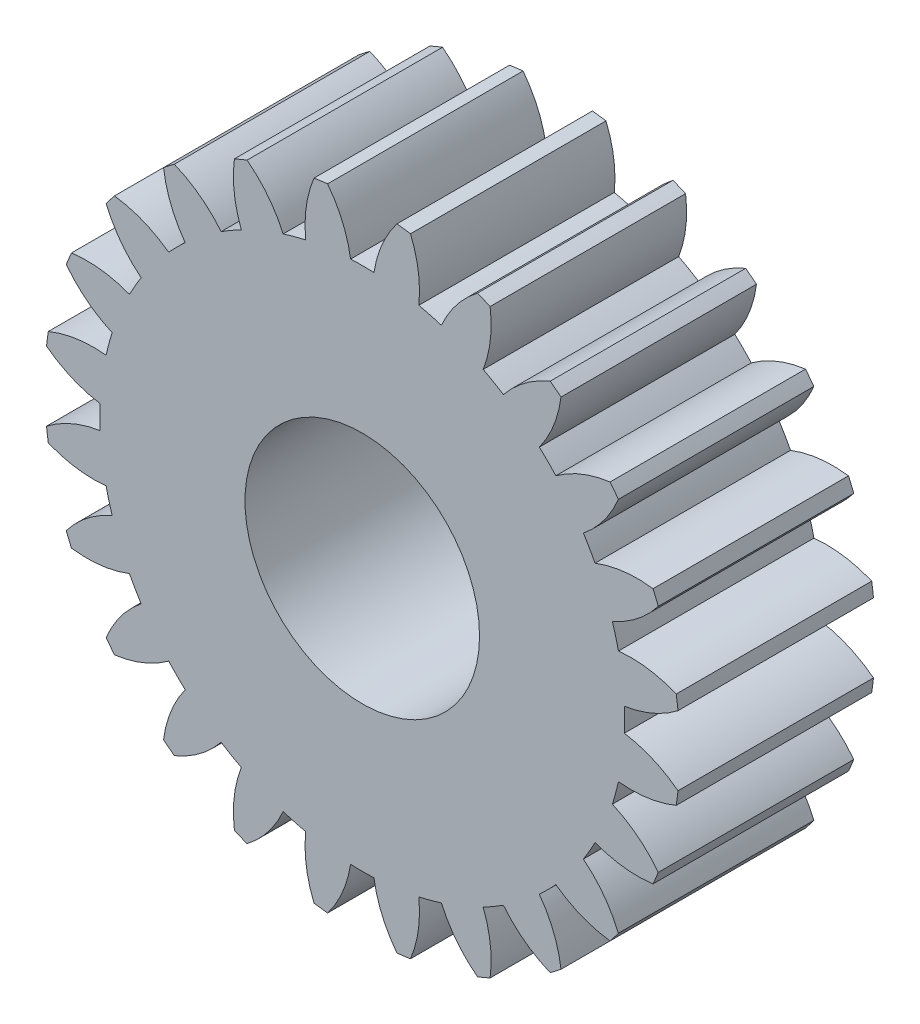
from build123d import *

# Parameters (mm, degrees)
SKETCH2_R           = 3.81
BOSS_EXTRUDE1_DEPTH = 6.35


with BuildPart() as part:
    # Sketch2 → Boss-Extrude1 (new body)
    with BuildSketch(Plane.XY):
        with BuildLine():
            ThreePointArc((-42.015017319, -22.945367918), (-41.531469039, -22.120633406), (-41.268457962, -21.20148645))
            ThreePointArc((-41.268457962, -21.20148645), (-40.889005651, -21.209938725), (-40.50955334, -21.20148645))
            ThreePointArc((-40.50955334, -21.20148645), (-40.246542262, -22.120633406), (-39.762993983, -22.945367918))
            ThreePointArc((-39.762993983, -22.945367918), (-39.542138505, -22.918710388), (-39.321909019, -22.887297981))
            ThreePointArc((-39.321909019, -22.887297981), (-39.068294246, -21.965514112), (-39.052137791, -21.009614053))
            ThreePointArc((-39.052137791, -21.009614053), (-38.683427394, -20.919568839), (-38.319092217, -20.813195084))
            ThreePointArc((-38.319092217, -20.813195084), (-37.827150287, -21.632950591), (-37.146621516, -22.304431452))
            ThreePointArc((-37.146621516, -22.304431452), (-36.940190983, -22.221520651), (-36.735595764, -22.13417901))
            ThreePointArc((-36.735595764, -22.13417901), (-36.729197926, -21.178163832), (-36.960997129, -20.250653679))
            ThreePointArc((-36.960997129, -20.250653679), (-36.628155651, -20.068247408), (-36.303766447, -19.871201369))
            ThreePointArc((-36.303766447, -19.871201369), (-35.616418695, -20.535700443), (-34.785286345, -21.008167342))
            ThreePointArc((-34.785286345, -21.008167342), (-34.607348655, -20.874653505), (-34.432330529, -20.737334819))
            ThreePointArc((-34.432330529, -20.737334819), (-34.673585627, -19.812239186), (-35.137543756, -18.976327224))
            ThreePointArc((-35.137543756, -18.976327224), (-34.863253794, -18.713990582), (-34.600917152, -18.43970062))
            ThreePointArc((-34.600917152, -18.43970062), (-33.76500519, -18.903658748), (-32.839909556, -19.144913847))
            ThreePointArc((-32.839909556, -19.144913847), (-32.702590871, -18.969895721), (-32.569077034, -18.791958031))
            ThreePointArc((-32.569077034, -18.791958031), (-33.041543932, -17.960825681), (-33.706043007, -17.273477928))
            ThreePointArc((-33.706043007, -17.273477928), (-33.508996967, -16.949088725), (-33.326590697, -16.616247247))
            ThreePointArc((-33.326590697, -16.616247247), (-32.399080544, -16.84804645), (-31.443065365, -16.841648612))
            ThreePointArc((-31.443065365, -16.841648612), (-31.355723725, -16.637053393), (-31.272812924, -16.430622859))
            ThreePointArc((-31.272812924, -16.430622859), (-31.944293785, -15.750094089), (-32.764049292, -15.258152159))
            ThreePointArc((-32.764049292, -15.258152159), (-32.657675537, -14.893816982), (-32.567630323, -14.525106585))
            ThreePointArc((-32.567630323, -14.525106585), (-31.611730264, -14.50895013), (-30.689946395, -14.255335357))
            ThreePointArc((-30.689946395, -14.255335357), (-30.658533987, -14.035105871), (-30.631876458, -13.814250393))
            ThreePointArc((-30.631876458, -13.814250393), (-31.456610969, -13.330702114), (-32.375757925, -13.067691036))
            ThreePointArc((-32.375757925, -13.067691036), (-32.367305651, -12.688238725), (-32.375757925, -12.308786414))
            ThreePointArc((-32.375757925, -12.308786414), (-31.456610969, -12.045775337), (-30.631876458, -11.562227057))
            ThreePointArc((-30.631876458, -11.562227057), (-30.658533987, -11.341371579), (-30.689946395, -11.121142093))
            ThreePointArc((-30.689946395, -11.121142093), (-31.611730264, -10.86752732), (-32.567630323, -10.851370865))
            ThreePointArc((-32.567630323, -10.851370865), (-32.657675537, -10.482660468), (-32.764049292, -10.118325291))
            ThreePointArc((-32.764049292, -10.118325291), (-31.944293785, -9.626383361), (-31.272812924, -8.945854591))
            ThreePointArc((-31.272812924, -8.945854591), (-31.355723725, -8.739424057), (-31.443065365, -8.534828838))
            ThreePointArc((-31.443065365, -8.534828838), (-32.399080544, -8.528431), (-33.326590697, -8.760230203))
            ThreePointArc((-33.326590697, -8.760230203), (-33.508996967, -8.427388725), (-33.706043007, -8.102999522))
            ThreePointArc((-33.706043007, -8.102999522), (-33.041543932, -7.415651769), (-32.569077034, -6.584519419))
            ThreePointArc((-32.569077034, -6.584519419), (-32.702590871, -6.406581729), (-32.839909556, -6.231563603))
            ThreePointArc((-32.839909556, -6.231563603), (-33.76500519, -6.472818702), (-34.600917152, -6.936776831))
            ThreePointArc((-34.600917152, -6.936776831), (-34.863253794, -6.662486868), (-35.137543756, -6.400150226))
            ThreePointArc((-35.137543756, -6.400150226), (-34.673585627, -5.564238264), (-34.432330529, -4.639142631))
            ThreePointArc((-34.432330529, -4.639142631), (-34.607348655, -4.501823945), (-34.785286345, -4.368310108))
            ThreePointArc((-34.785286345, -4.368310108), (-35.616418695, -4.840777007), (-36.303766447, -5.505276082))
            ThreePointArc((-36.303766447, -5.505276082), (-36.628155651, -5.308230042), (-36.960997129, -5.125823771))
            ThreePointArc((-36.960997129, -5.125823771), (-36.729197926, -4.198313618), (-36.735595764, -3.24229844))
            ThreePointArc((-36.735595764, -3.24229844), (-36.940190983, -3.154956799), (-37.146621516, -3.072045999))
            ThreePointArc((-37.146621516, -3.072045999), (-37.827150287, -3.743526859), (-38.319092217, -4.563282366))
            ThreePointArc((-38.319092217, -4.563282366), (-38.683427394, -4.456908611), (-39.052137791, -4.366863397))
            ThreePointArc((-39.052137791, -4.366863397), (-39.068294246, -3.410963338), (-39.321909019, -2.489179469))
            ThreePointArc((-39.321909019, -2.489179469), (-39.542138505, -2.457767062), (-39.762993983, -2.431109532))
            ThreePointArc((-39.762993983, -2.431109532), (-40.246542262, -3.255844044), (-40.50955334, -4.174991))
            ThreePointArc((-40.50955334, -4.174991), (-40.889005651, -4.166538725), (-41.268457962, -4.174991))
            ThreePointArc((-41.268457962, -4.174991), (-41.531469039, -3.255844044), (-42.015017319, -2.431109532))
            ThreePointArc((-42.015017319, -2.431109532), (-42.235872797, -2.457767062), (-42.456102283, -2.489179469))
            ThreePointArc((-42.456102283, -2.489179469), (-42.709717056, -3.410963338), (-42.725873511, -4.366863397))
            ThreePointArc((-42.725873511, -4.366863397), (-43.094583907, -4.456908611), (-43.458919085, -4.563282366))
            ThreePointArc((-43.458919085, -4.563282366), (-43.950861015, -3.743526859), (-44.631389785, -3.072045999))
            ThreePointArc((-44.631389785, -3.072045999), (-44.837820319, -3.154956799), (-45.042415538, -3.24229844))
            ThreePointArc((-45.042415538, -3.24229844), (-45.048813376, -4.198313618), (-44.817014173, -5.125823771))
            ThreePointArc((-44.817014173, -5.125823771), (-45.149855651, -5.308230042), (-45.474244854, -5.505276082))
            ThreePointArc((-45.474244854, -5.505276082), (-46.161592607, -4.840777007), (-46.992724957, -4.368310108))
            ThreePointArc((-46.992724957, -4.368310108), (-47.170662646, -4.501823945), (-47.345680772, -4.639142631))
            ThreePointArc((-47.345680772, -4.639142631), (-47.104425674, -5.564238264), (-46.640467545, -6.400150226))
            ThreePointArc((-46.640467545, -6.400150226), (-46.914757508, -6.662486868), (-47.177094149, -6.936776831))
            ThreePointArc((-47.177094149, -6.936776831), (-48.013006112, -6.472818702), (-48.938101745, -6.231563603))
            ThreePointArc((-48.938101745, -6.231563603), (-49.075420431, -6.406581729), (-49.208934268, -6.584519419))
            ThreePointArc((-49.208934268, -6.584519419), (-48.736467369, -7.415651769), (-48.071968294, -8.102999522))
            ThreePointArc((-48.071968294, -8.102999522), (-48.269014334, -8.427388725), (-48.451420605, -8.760230203))
            ThreePointArc((-48.451420605, -8.760230203), (-49.378930758, -8.528431), (-50.334945936, -8.534828838))
            ThreePointArc((-50.334945936, -8.534828838), (-50.422287577, -8.739424057), (-50.505198377, -8.945854591))
            ThreePointArc((-50.505198377, -8.945854591), (-49.833717517, -9.626383361), (-49.01396201, -10.118325291))
            ThreePointArc((-49.01396201, -10.118325291), (-49.120335765, -10.482660468), (-49.210380979, -10.851370865))
            ThreePointArc((-49.210380979, -10.851370865), (-50.166281038, -10.86752732), (-51.088064907, -11.121142093))
            ThreePointArc((-51.088064907, -11.121142093), (-51.119477314, -11.341371579), (-51.146134844, -11.562227057))
            ThreePointArc((-51.146134844, -11.562227057), (-50.321400332, -12.045775337), (-49.402253376, -12.308786414))
            ThreePointArc((-49.402253376, -12.308786414), (-49.410705651, -12.688238725), (-49.402253376, -13.067691036))
            ThreePointArc((-49.402253376, -13.067691036), (-50.321400332, -13.330702114), (-51.146134844, -13.814250393))
            ThreePointArc((-51.146134844, -13.814250393), (-51.119477314, -14.035105871), (-51.088064907, -14.255335357))
            ThreePointArc((-51.088064907, -14.255335357), (-50.166281038, -14.50895013), (-49.210380979, -14.525106585))
            ThreePointArc((-49.210380979, -14.525106585), (-49.120335765, -14.893816982), (-49.01396201, -15.258152159))
            ThreePointArc((-49.01396201, -15.258152159), (-49.833717517, -15.750094089), (-50.505198377, -16.430622859))
            ThreePointArc((-50.505198377, -16.430622859), (-50.422287577, -16.637053393), (-50.334945936, -16.841648612))
            ThreePointArc((-50.334945936, -16.841648612), (-49.378930758, -16.84804645), (-48.451420605, -16.616247247))
            ThreePointArc((-48.451420605, -16.616247247), (-48.269014334, -16.949088725), (-48.071968294, -17.273477928))
            ThreePointArc((-48.071968294, -17.273477928), (-48.736467369, -17.960825681), (-49.208934268, -18.791958031))
            ThreePointArc((-49.208934268, -18.791958031), (-49.075420431, -18.969895721), (-48.938101745, -19.144913847))
            ThreePointArc((-48.938101745, -19.144913847), (-48.013006112, -18.903658748), (-47.177094149, -18.43970062))
            ThreePointArc((-47.177094149, -18.43970062), (-46.914757508, -18.713990582), (-46.640467545, -18.976327224))
            ThreePointArc((-46.640467545, -18.976327224), (-47.104425674, -19.812239186), (-47.345680772, -20.737334819))
            ThreePointArc((-47.345680772, -20.737334819), (-47.170662646, -20.874653505), (-46.992724957, -21.008167342))
            ThreePointArc((-46.992724957, -21.008167342), (-46.161592607, -20.535700443), (-45.474244854, -19.871201369))
            ThreePointArc((-45.474244854, -19.871201369), (-45.149855651, -20.068247408), (-44.817014173, -20.250653679))
            ThreePointArc((-44.817014173, -20.250653679), (-45.048813376, -21.178163832), (-45.042415538, -22.13417901))
            ThreePointArc((-45.042415538, -22.13417901), (-44.837820319, -22.221520651), (-44.631389785, -22.304431452))
            ThreePointArc((-44.631389785, -22.304431452), (-43.950861015, -21.632950591), (-43.458919085, -20.813195084))
            ThreePointArc((-43.458919085, -20.813195084), (-43.094583907, -20.919568839), (-42.725873511, -21.009614053))
            ThreePointArc((-42.725873511, -21.009614053), (-42.709717056, -21.965514112), (-42.456102283, -22.887297981))
            ThreePointArc((-42.456102283, -22.887297981), (-42.235872797, -22.918710388), (-42.015017319, -22.945367918))
        make_face()
        with Locations((-40.889005651, -12.688238725)):
            Circle(SKETCH2_R, mode=Mode.SUBTRACT)
    extrude(amount=BOSS_EXTRUDE1_DEPTH)


solid = part.part
